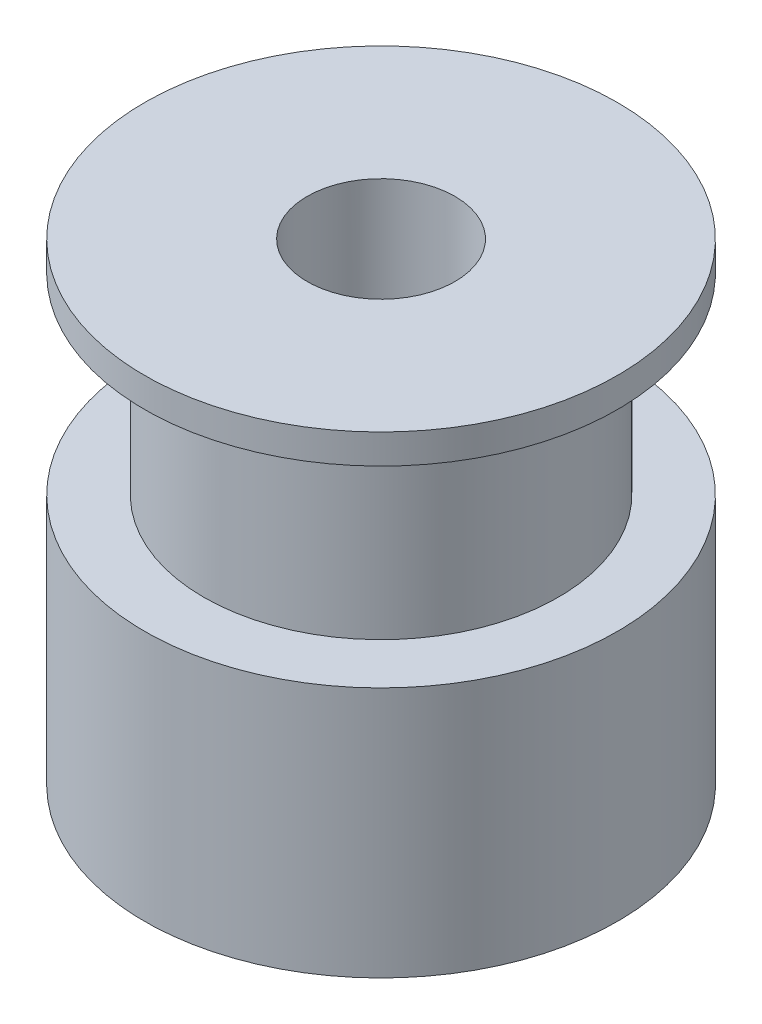
from build123d import *

# Parameters (mm, degrees)
ESQUISSE2_R             = 1.5
ENL_V_MAT_EXTRU_1_DEPTH = 9
ESQUISSE3_R             = 1.5
ENL_V_MAT_EXTRU_2_DEPTH = 9.0000001


with BuildPart() as part:
    # Esquisse1 → Révolution1 (revolve)
    with BuildSketch(Plane.XY):
        Polygon((-2.5, 0), (-2.5, 16), (-8, 16), (-8, 15), (-6, 15), (-6, 8.5), (-8, 8.5), (-8, 0), align=None)
    revolve(axis=Axis((0, 0, 0), (0, 1, 0)))

    # Esquisse2 → Enlèv. mat.-Extru.1 (cut, through all)
    with BuildSketch(Plane(origin=(0, 0, 0), x_dir=(0, 0, -1), z_dir=(1, 0, 0))):
        with Locations((0, 4.25)):
            Circle(ESQUISSE2_R)
    extrude(amount=-ENL_V_MAT_EXTRU_1_DEPTH, mode=Mode.SUBTRACT)

    # Esquisse3 → Enlèv. mat.-Extru.2 (cut, through all)
    with BuildSketch(Plane.XY):
        with Locations((0, 4.25)):
            Circle(ESQUISSE3_R)
    extrude(amount=-ENL_V_MAT_EXTRU_2_DEPTH, mode=Mode.SUBTRACT)


solid = part.part
